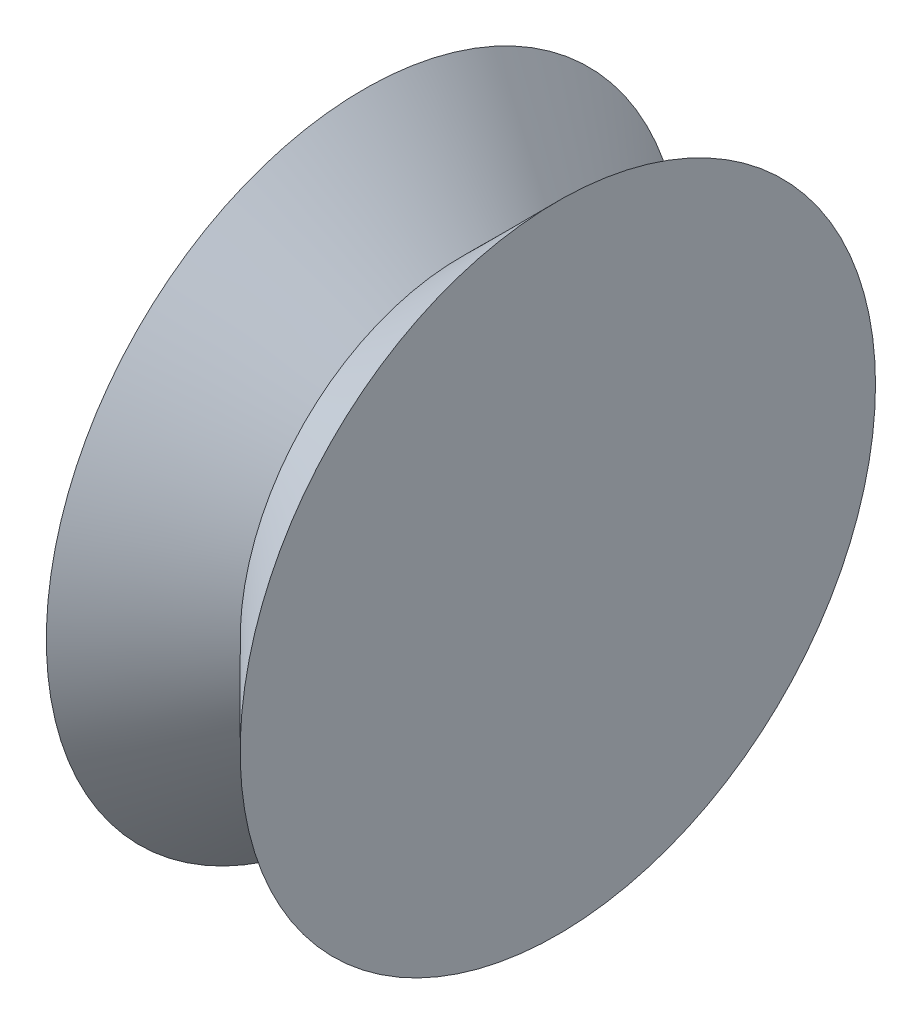
from build123d import *


with BuildPart() as part:
    # Sketch1 → Revolve1 (revolve)
    with BuildSketch(Plane(origin=(0, 0, 0), x_dir=(1, 0, 0), z_dir=(0, 1, 0))):
        Polygon((-5.698818898, 5.486220472), (-5.698818898, -3.513779528), (-0.206692913, -3.513779528), (-0.206692913, 5.486220472), (-2.952755906, 2.74015748), align=None)
    revolve(axis=Axis((-0.206692913, 0, 3.513779528), (-1, 0, 0)))


solid = part.part
